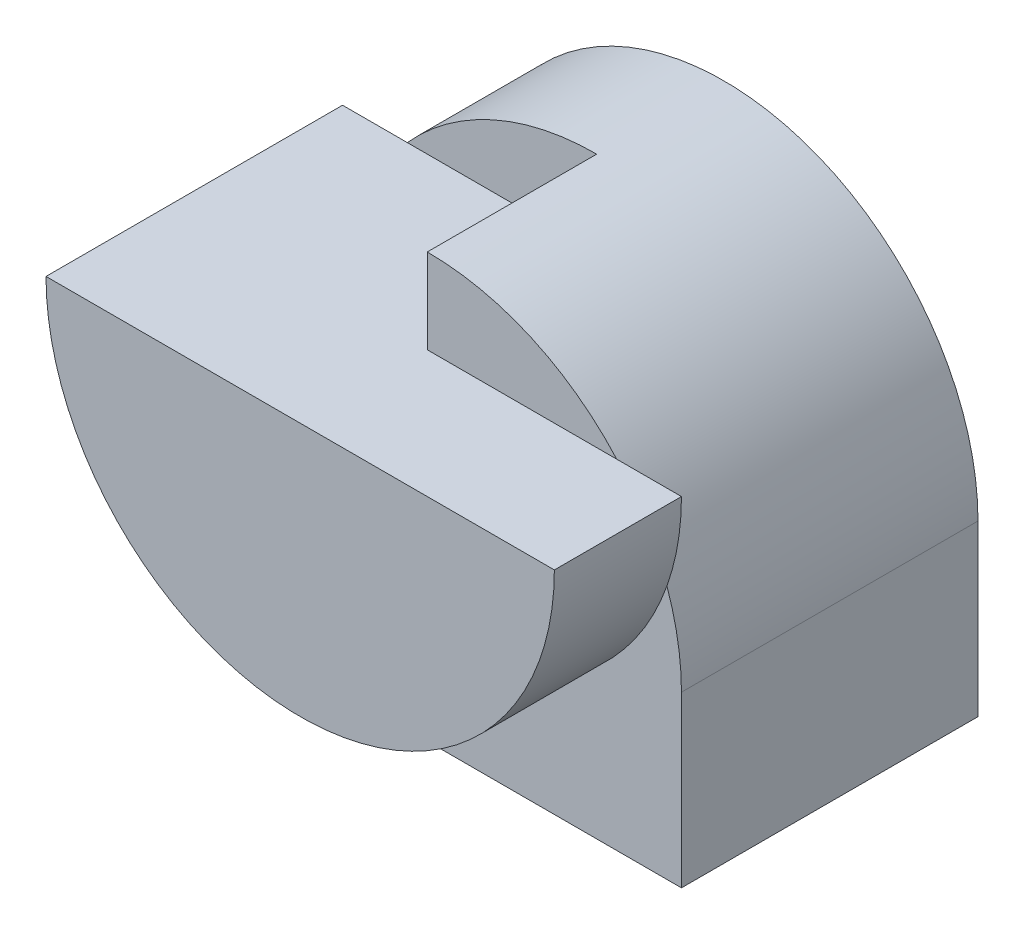
from build123d import *

# Parameters (mm, degrees)
BOSS_EXTRUDE7_DEPTH      = 3.5
SKETCH12_W               = 3
SKETCH12_H               = 2
CUT_EXTRUDE5_DEPTH       = 5.5
BOSS_EXTRUDE8_DEPTH      = 1.5
BOSS_EXTRUDE8_DEPTH_BACK = 2
CUT_EXTRUDE6_DEPTH       = 2


with BuildPart() as part:
    # Sketch11 → Boss-Extrude7 (new body)
    with BuildSketch(Plane.XY):
        with BuildLine():
            Line((3, 0), (3, -2))
            Line((3, -2), (-3, -2))
            Line((-3, -2), (-3, 0))
            ThreePointArc((-3, 0), (0, 3), (3, 0))
        make_face()
    extrude(amount=BOSS_EXTRUDE7_DEPTH)

    # Sketch12 → Cut-Extrude5 (cut)
    with BuildSketch(Plane(origin=(0, -2, 0), x_dir=(-1, 0, 0), z_dir=(0, -1, 0))):
        with Locations((1.5, -2.5)):
            Rectangle(SKETCH12_W, SKETCH12_H)
    extrude(amount=-CUT_EXTRUDE5_DEPTH, mode=Mode.SUBTRACT)

    # Sketch13 → Boss-Extrude8 (add, two sides)
    with BuildSketch(Plane.XY.offset(3.5)) as boss_extrude8_sk:
        with BuildLine():
            Line((-3, 2), (3, 2))
            ThreePointArc((3, 2), (0, -1), (-3, 2))
        make_face()
    extrude(amount=BOSS_EXTRUDE8_DEPTH)
    extrude(boss_extrude8_sk.sketch, amount=-BOSS_EXTRUDE8_DEPTH_BACK)

    # Sketch14 → Cut-Extrude6 (cut)
    with BuildSketch(Plane(origin=(0, 0, 1.5), x_dir=(-1, 0, 0), z_dir=(0, 0, -1))):
        with BuildLine():
            ThreePointArc((-3, 2), (-2.956795679, 1.492694064), (-2.828427125, 1))
            ThreePointArc((-2.828427125, 1), (-2.58113883, 1.528961196), (-2.236067977, 2))
            Line((-2.236067977, 2), (-3, 2))
        make_face()
    extrude(amount=-CUT_EXTRUDE6_DEPTH, mode=Mode.SUBTRACT)


solid = part.part
